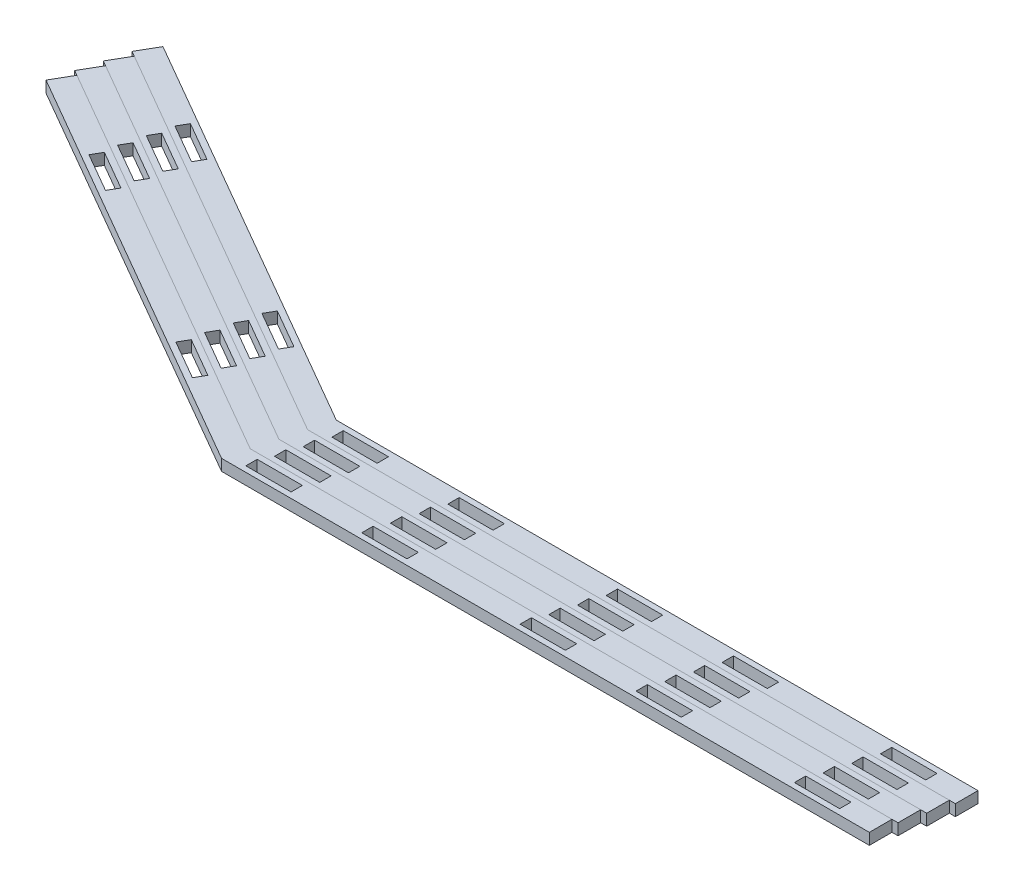
from build123d import *

# Parameters (mm, degrees)
SKETCH4_W           = 25.4
SKETCH4_H           = 6.35
BOSS_EXTRUDE2_DEPTH = 6.35
LPATTERN1_COUNT     = 4
LPATTERN1_PITCH     = 13.148007486


with BuildPart() as part:
    # Sketch4 → Boss-Extrude2 (new body)
    with BuildSketch(Plane(origin=(0, 0, 0), x_dir=(1, 0, 0), z_dir=(0, 1, 0))):
        Polygon((-596.849633079, 128.276111157), (-590.499633079, 139.274633785), (-360.267413785, 6.35), (0, 6.35), (0, -6.35), (-363.670368529, -6.35), align=None)
        Polygon((-548.51841191, 104.038241814), (-526.521366654, 91.338241814), (-523.346366654, 96.837503128), (-545.34341191, 109.537503128), align=None, mode=Mode.SUBTRACT)
        Polygon((-433.033924315, 37.363241814), (-411.036879059, 24.663241814), (-407.861879059, 30.162503128), (-429.858924315, 42.862503128), align=None, mode=Mode.SUBTRACT)
        with Locations((-340.498292116, 0)):
            Rectangle(SKETCH4_W, SKETCH4_H, mode=Mode.SUBTRACT)
        with Locations((-275.418975234, 0)):
            Rectangle(SKETCH4_W, SKETCH4_H, mode=Mode.SUBTRACT)
        with Locations((-186.518975234, 0)):
            Rectangle(SKETCH4_W, SKETCH4_H, mode=Mode.SUBTRACT)
        with Locations((-121.439658352, 0)):
            Rectangle(SKETCH4_W, SKETCH4_H, mode=Mode.SUBTRACT)
        with Locations((-32.539658352, 0)):
            Rectangle(SKETCH4_W, SKETCH4_H, mode=Mode.SUBTRACT)
    extrude(amount=BOSS_EXTRUDE2_DEPTH)


with BuildPart() as lpattern1_1:
    # LPattern1: pattern copy
    add(part.part.moved(Location(Vector(0.258819045, 0, -0.965925826) * (1 * LPATTERN1_PITCH))))


with BuildPart() as lpattern1_2:
    # LPattern1: pattern copy
    add(part.part.moved(Location(Vector(0.258819045, 0, -0.965925826) * (2 * LPATTERN1_PITCH))))


with BuildPart() as lpattern1_3:
    # LPattern1: pattern copy
    add(part.part.moved(Location(Vector(0.258819045, 0, -0.965925826) * (3 * LPATTERN1_PITCH))))


solid = Compound([part.part, lpattern1_1.part, lpattern1_2.part, lpattern1_3.part])
